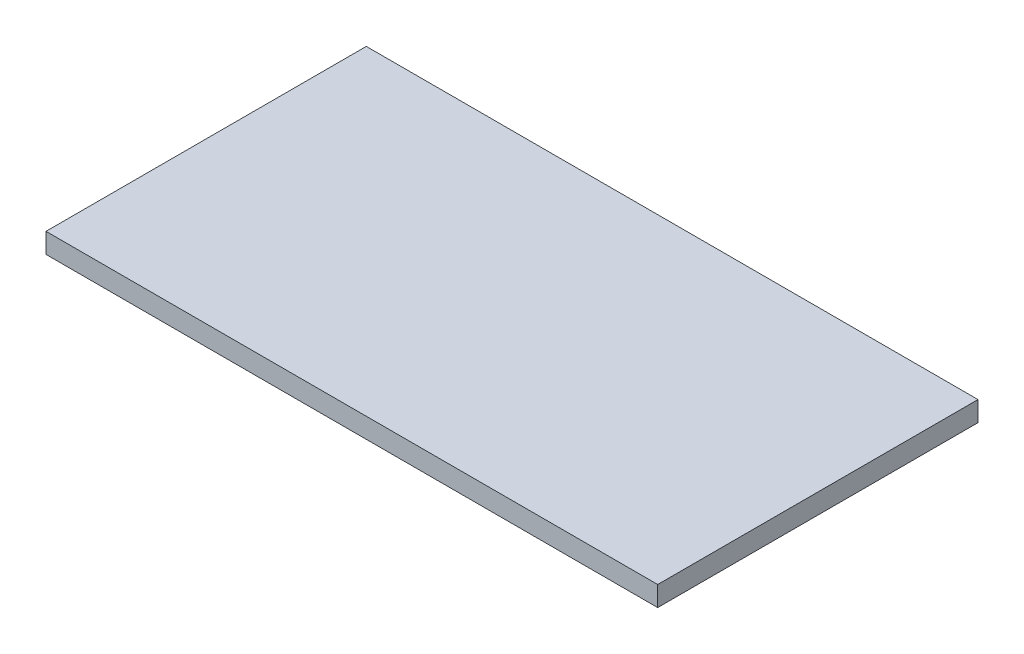
from build123d import *

# Parameters (mm, degrees)
SKETCH1_W           = 550
SKETCH1_H           = 288
BOSS_EXTRUDE1_DEPTH = 18


with BuildPart() as part:
    # Sketch1 → Boss-Extrude1 (new body)
    with BuildSketch(Plane(origin=(0, 0, 0), x_dir=(1, 0, 0), z_dir=(0, 1, 0))):
        Rectangle(SKETCH1_W, SKETCH1_H)
    extrude(amount=BOSS_EXTRUDE1_DEPTH)


solid = part.part
